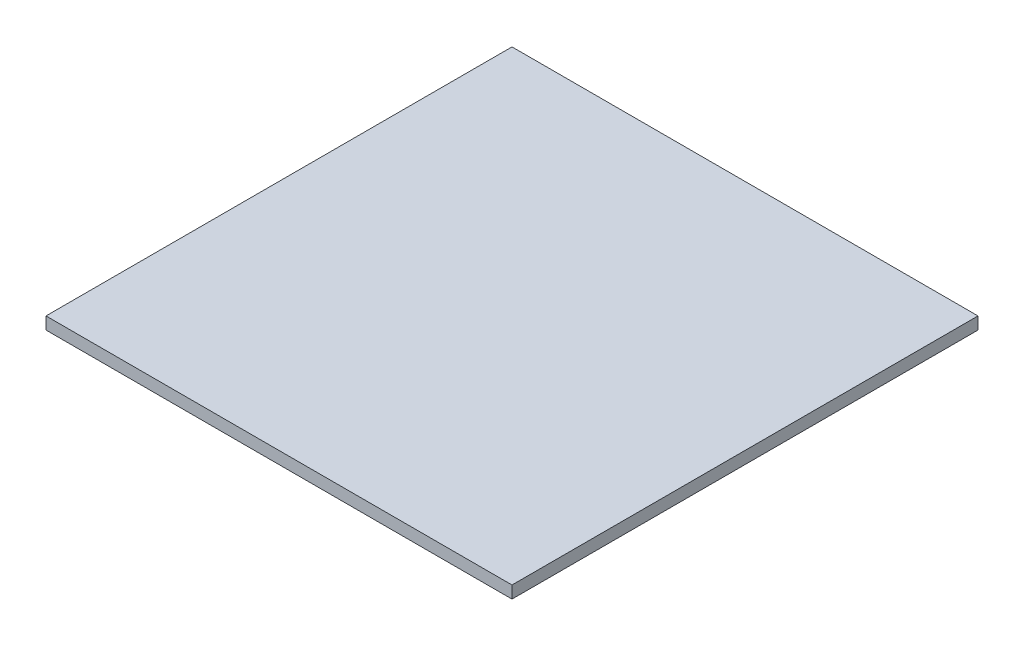
from build123d import *

# Parameters (mm, degrees)
SKETCH1_W           = 603.25
SKETCH1_H           = 603.25
BOSS_EXTRUDE1_DEPTH = 15.875


with BuildPart() as part:
    # Sketch1 → Boss-Extrude1 (new body)
    with BuildSketch(Plane(origin=(0, 0, 0), x_dir=(1, 0, 0), z_dir=(0, 1, 0))):
        with Locations((301.625, 301.625)):
            Rectangle(SKETCH1_W, SKETCH1_H)
    extrude(amount=BOSS_EXTRUDE1_DEPTH)


solid = part.part
